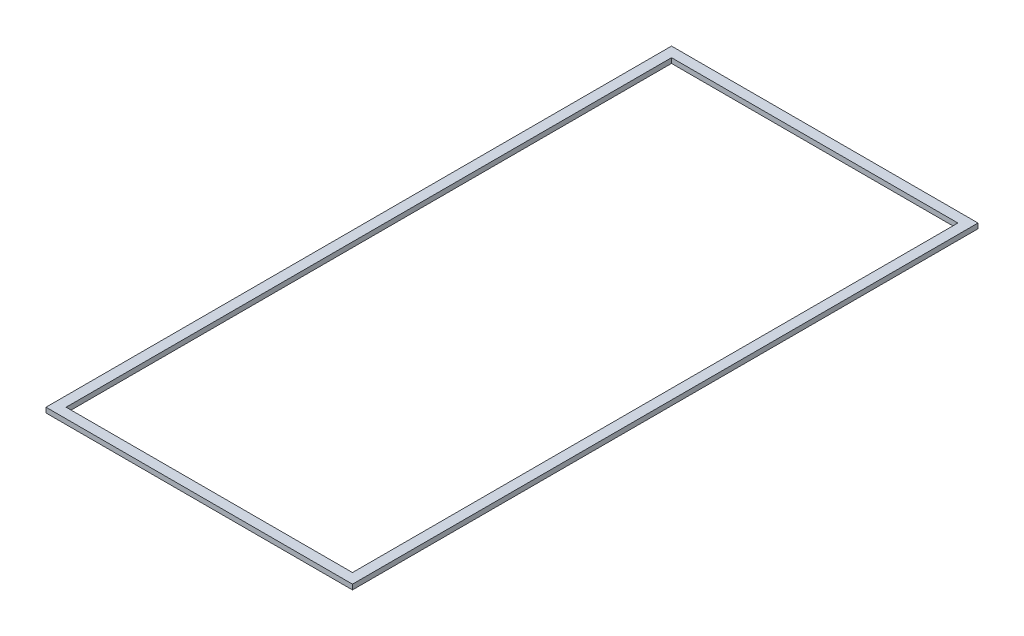
from build123d import *

# Parameters (mm, degrees)
SKETCH_1_W      = 610
SKETCH_1_H      = 1245
SKETCH_1_W_2    = 570
SKETCH_1_H_2    = 1205
EXTRUDE_1_DEPTH = 10


with BuildPart() as part:
    # Эскиз1 → Вытянуть-Тонкостенный1 (new body)
    with BuildSketch(Plane(origin=(0, 0, 0), x_dir=(1, 0, 0), z_dir=(0, 1, 0))):
        with Locations((305, 622.5)):
            Rectangle(SKETCH_1_W, SKETCH_1_H)
        with Locations((305, 622.5)):
            Rectangle(SKETCH_1_W_2, SKETCH_1_H_2, mode=Mode.SUBTRACT)
    extrude(amount=EXTRUDE_1_DEPTH)


solid = part.part
